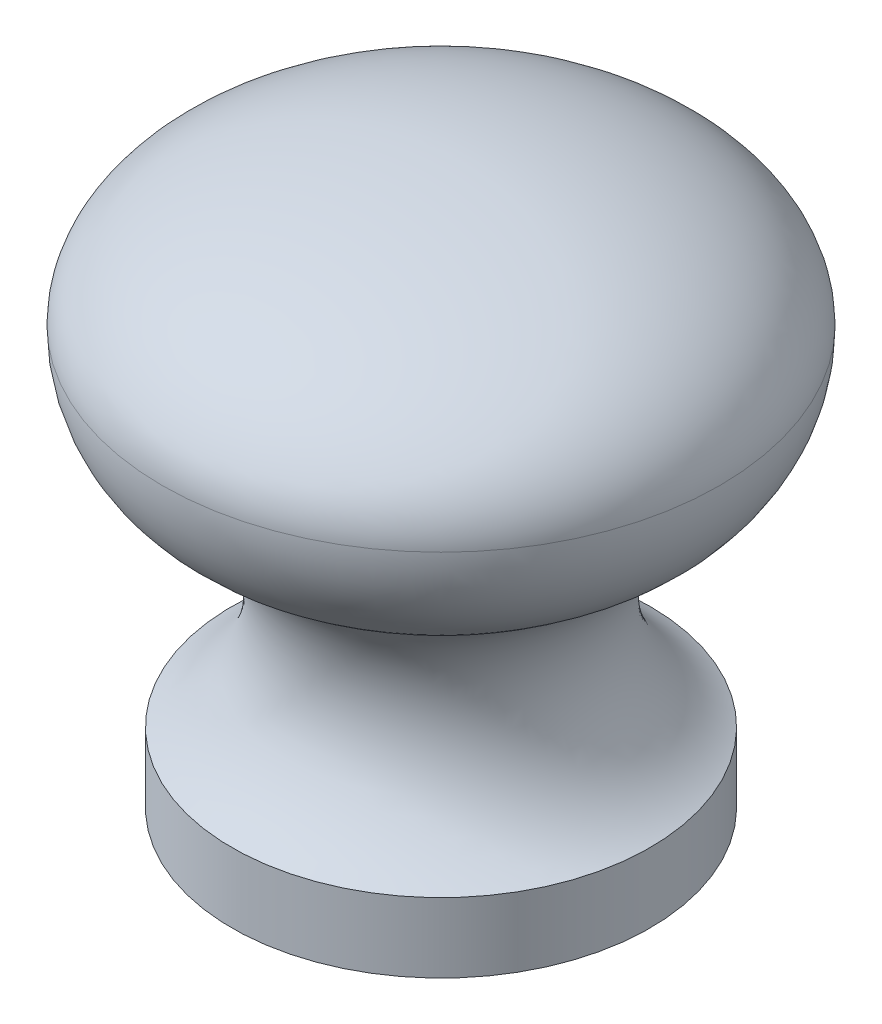
from build123d import *

# Parameters (mm, degrees)
F_8_32_TAPPED_HOLE1_D           = 3.4544
F_8_32_TAPPED_HOLE1_DEPTH       = 15.07744
F_8_32_TAPPED_HOLE1_CBORE_D     = 4.1656
F_8_32_TAPPED_HOLE1_CBORE_DEPTH = 12.7
F_8_32_TAPPED_HOLE1_TIP         = 1.037806461


with BuildPart() as part:
    # Sketch1 → Base-Revolve (revolve)
    with BuildSketch(Plane.XY):
        with BuildLine():
            Line((0, 0), (-9.525, 0))
            Line((-9.525, 0), (-9.525, 3.175))
            ThreePointArc((-9.525, 3.175), (-6.350520234, 8.282737448), (-9.387318408, 13.47351393))
            ThreePointArc((-9.387318408, 13.47351393), (-11.809371387, 15.806889756), (-12.7, 19.05))
            add(Edge.make_bspline(
                [(0, 25.4), (-12.7, 25.4), (-12.7, 19.05)],
                knots=[4.71238898, 4.71238898, 4.71238898, 6.283185307, 6.283185307, 6.283185307], degree=2, weights=[1, 0.707106781, 1]))
            Line((0, 25.4), (0, 0))
        make_face()
    revolve(axis=Axis((0, 0, 0), (0, 1, 0)))

    # #8-32 Tapped Hole1
    with Locations(Plane.XZ):
        with Locations((0, 0)):
            CounterBoreHole(F_8_32_TAPPED_HOLE1_D / 2, F_8_32_TAPPED_HOLE1_CBORE_D / 2, F_8_32_TAPPED_HOLE1_CBORE_DEPTH, depth=F_8_32_TAPPED_HOLE1_DEPTH)
            with Locations((0, 0, -(F_8_32_TAPPED_HOLE1_DEPTH + F_8_32_TAPPED_HOLE1_TIP / 2))):  # 118° drill point
                Cone(0, F_8_32_TAPPED_HOLE1_D / 2, F_8_32_TAPPED_HOLE1_TIP, mode=Mode.SUBTRACT)


solid = part.part
